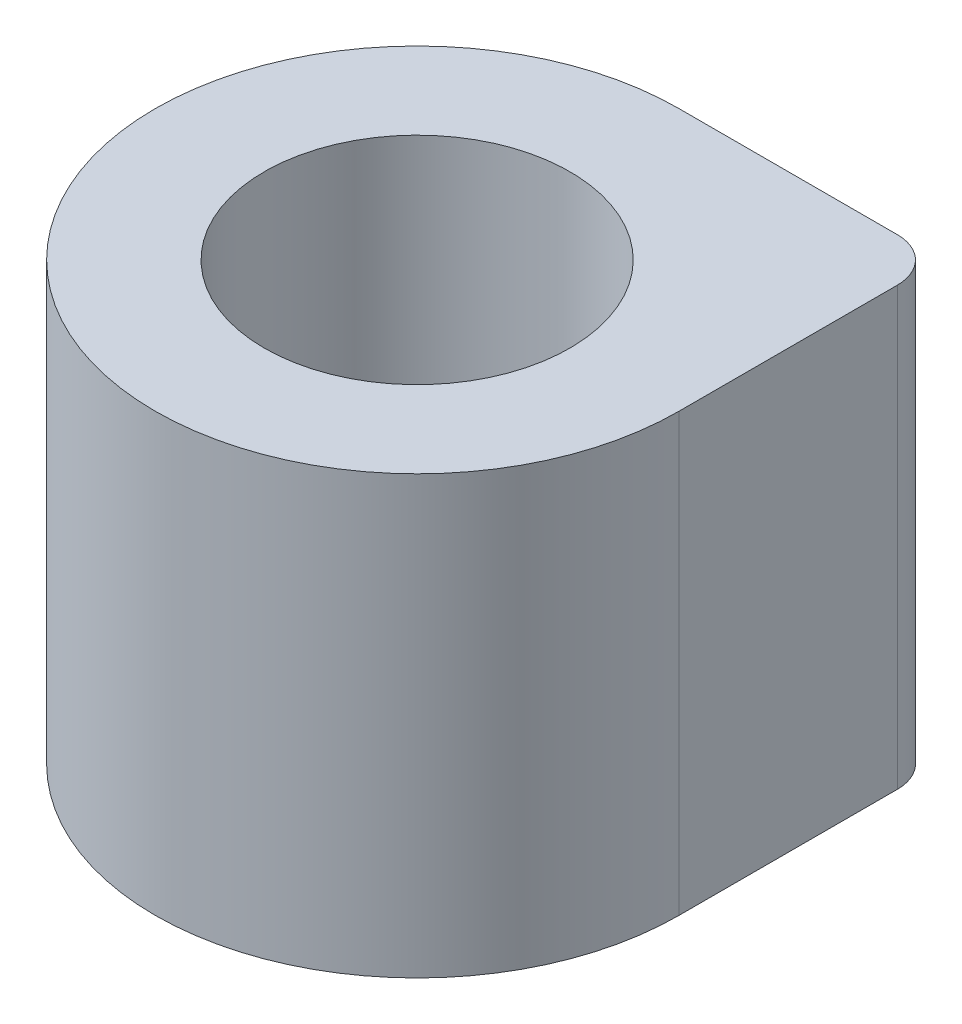
from build123d import *

# Parameters (mm, degrees)
BOSS_EXTRUDE1_DEPTH = 10
SKETCH2_R           = 3.5
CUT_EXTRUDE1_DEPTH  = 8
FILLET1_R           = 1


with BuildPart() as part:
    # Sketch1 → Boss-Extrude1 (new body)
    with BuildSketch(Plane(origin=(0, 0, 0), x_dir=(1, 0, 0), z_dir=(0, 1, 0))):
        with BuildLine():
            Line((0, 6), (6, 6))
            Line((6, 6), (6, 0))
            ThreePointArc((6, 0), (-4.242640687, -4.242640687), (0, 6))
        make_face()
    extrude(amount=BOSS_EXTRUDE1_DEPTH)

    # Sketch2 → Cut-Extrude1 (cut)
    with BuildSketch(Plane(origin=(0, 10, 0), x_dir=(1, 0, 0), z_dir=(0, 1, 0))):
        with Locations(Location((0, 0, 0), (0, 0, 270))):  # turned: the seam where the file's is
            Circle(SKETCH2_R)
    extrude(amount=-CUT_EXTRUDE1_DEPTH, mode=Mode.SUBTRACT)

    # Fillet1
    fillet1_edges = [part.edges().sort_by_distance(p)[0] for p in [
        (6, 5, -6),
    ]]
    fillet(fillet1_edges, radius=FILLET1_R)


solid = part.part
